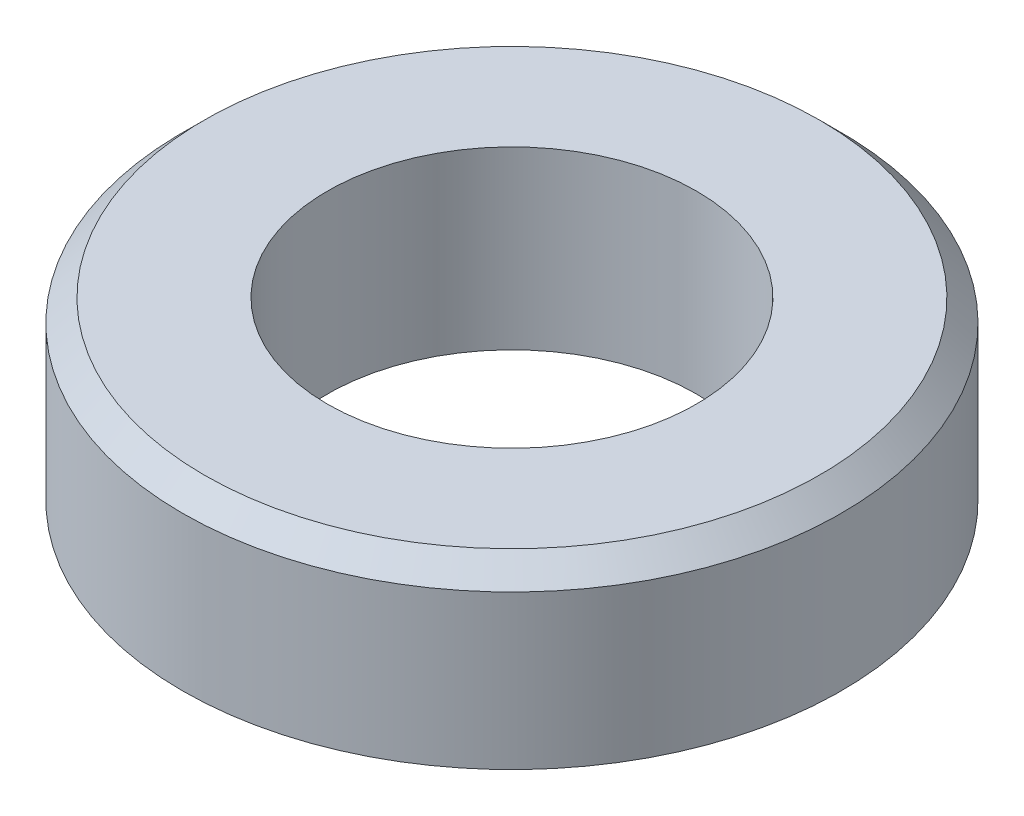
from build123d import *

# Parameters (mm, degrees)
SKETCH1_R           = 7.5
SKETCH1_R_2         = 4.2
BOSS_EXTRUDE1_DEPTH = 4
CHAMFER1_SIZE       = 0.5


with BuildPart() as part:
    # Sketch1 → Boss-Extrude1 (new body)
    with BuildSketch(Plane(origin=(0, 0, 0), x_dir=(1, 0, 0), z_dir=(0, 1, 0))):
        Circle(SKETCH1_R)
        Circle(SKETCH1_R_2, mode=Mode.SUBTRACT)
    extrude(amount=BOSS_EXTRUDE1_DEPTH)

    # Chamfer1
    chamfer1_edges = [part.edges().sort_by_distance(p)[0] for p in [
        (-7.5, 4, 0),
    ]]
    chamfer(chamfer1_edges, length=CHAMFER1_SIZE)


solid = part.part
